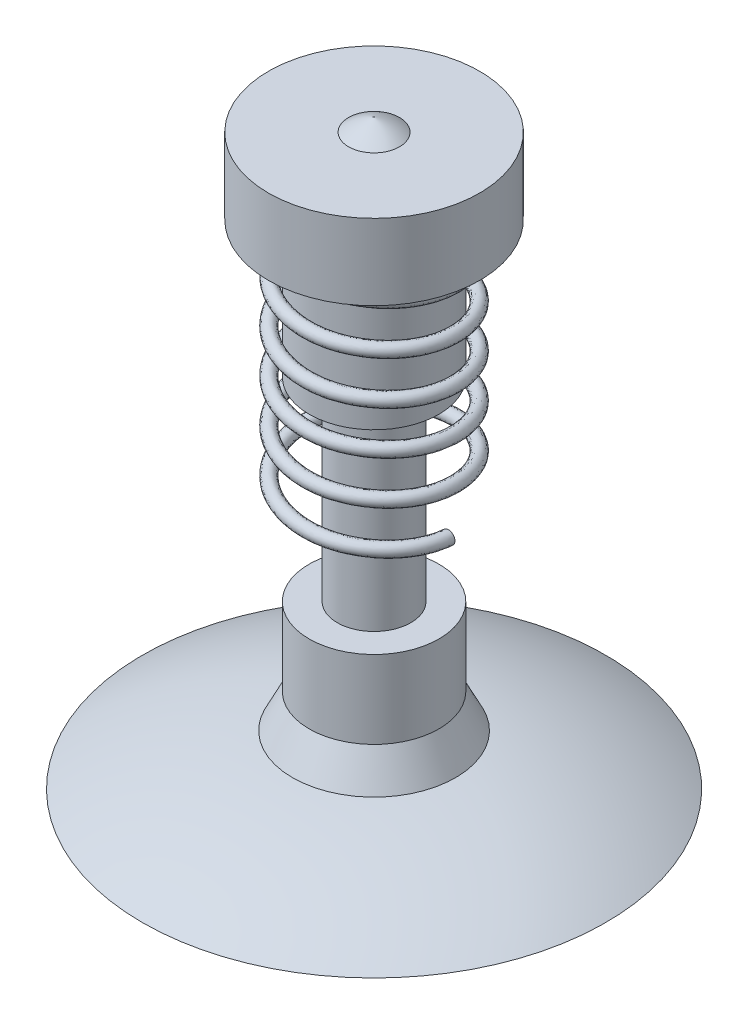
from build123d import *

# Parameters (mm, degrees)
SWEEP1_PITCH       = 0.2
SWEEP1_HEIGHT      = 1.1
SWEEP1_RADIUS      = 0.344
SWEEP1_START_ANGLE = -90
SKETCH7_R          = 0.03


with BuildPart() as part:
    # Sketch5 → Revolve2 (revolve)
    with BuildSketch(Plane.XY):
        with BuildLine():
            Line((0, 2.69), (0, 0))
            Line((0, 0), (1.071186722, 0))
            ThreePointArc((1.071186722, 0), (0.736424186, 0.152787779), (0.377431001, 0.233620658))
            Line((0.377431001, 0.233620658), (0.3, 0.3899871))
            Line((0.3, 0.3899871), (0.3, 0.750229409))
            Line((0.3, 0.750229409), (0.17, 0.750229409))
            Line((0.17, 0.750229409), (0.17, 1.560754687))
            Line((0.17, 1.560754687), (0.3, 1.65))
            Line((0.3, 1.65), (0.3, 2.28))
            Line((0.3, 2.28), (0.488304392, 2.28))
            Line((0.488304392, 2.28), (0.488304392, 2.63))
            Line((0.488304392, 2.63), (0.117651299, 2.63))
            ThreePointArc((0.117651299, 2.63), (0.061347487, 2.664944958), (0, 2.69))
        make_face()
    revolve(axis=Axis((0, 2.69, 0), (0, -1, 0)))

    # Sweep1: sweep along a helix
    with BuildLine() as sweep1_path:
        add(Helix(SWEEP1_PITCH, SWEEP1_HEIGHT, SWEEP1_RADIUS, center=(0, 2.28, 0), direction=(0, -1, 0), lefthand=True, mode=Mode.PRIVATE).rotate(Axis((0, 2.28, 0), (0, -1, 0)), SWEEP1_START_ANGLE))
    # Sketch7 → Sweep1 (sweep)
    with BuildSketch(Plane.XY):
        with Locations((0.344, 2.18)):
            Circle(SKETCH7_R)
    sweep(path=sweep1_path.line, is_frenet=True)


solid = part.part
